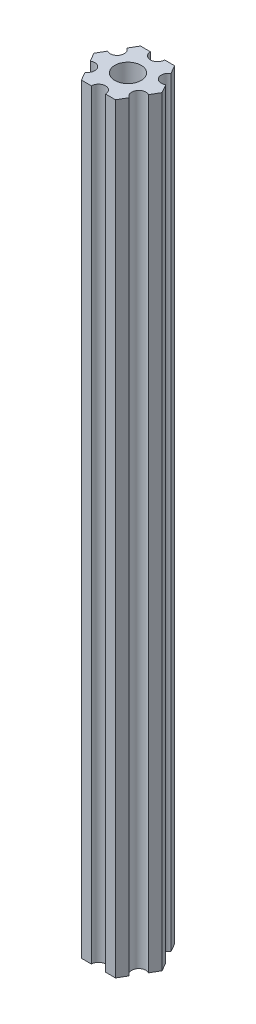
from build123d import *

# Parameters (mm, degrees)
ESBO_O1_R                = 2.79
RESSALTO_EXTRUS_O1_DEPTH = 161


with BuildPart() as part:
    # Esboço1 → Ressalto-extrusão1 (new body)
    with BuildSketch(Plane(origin=(0, 85, 0), x_dir=(1, 0, 0), z_dir=(0, 1, 0))):
        with BuildLine():
            Line((6.162658774, -1.825961894), (7.216878365, 0))
            Line((7.216878365, 0), (6.162658774, 1.825961894))
            ThreePointArc((6.162658774, 1.825961894), (4.113620668, 2.375), (4.662658774, 4.424038106))
            Line((4.662658774, 4.424038106), (3.608439182, 6.25))
            Line((3.608439182, 6.25), (1.5, 6.25))
            ThreePointArc((1.5, 6.25), (0, 4.75), (-1.5, 6.25))
            Line((-1.5, 6.25), (-3.608439182, 6.25))
            Line((-3.608439182, 6.25), (-4.662658774, 4.424038106))
            ThreePointArc((-4.662658774, 4.424038106), (-4.113620668, 2.375), (-6.162658774, 1.825961894))
            Line((-6.162658774, 1.825961894), (-7.216878365, 0))
            Line((-7.216878365, 0), (-6.162658774, -1.825961894))
            ThreePointArc((-6.162658774, -1.825961894), (-4.113620668, -2.375), (-4.662658774, -4.424038106))
            Line((-4.662658774, -4.424038106), (-3.608439182, -6.25))
            Line((-3.608439182, -6.25), (-1.5, -6.25))
            ThreePointArc((-1.5, -6.25), (0, -4.75), (1.5, -6.25))
            Line((1.5, -6.25), (3.608439182, -6.25))
            Line((3.608439182, -6.25), (4.662658774, -4.424038106))
            ThreePointArc((4.662658774, -4.424038106), (4.113620668, -2.375), (6.162658774, -1.825961894))
        make_face()
        Circle(ESBO_O1_R, mode=Mode.SUBTRACT)
    extrude(amount=-RESSALTO_EXTRUS_O1_DEPTH)


solid = part.part
